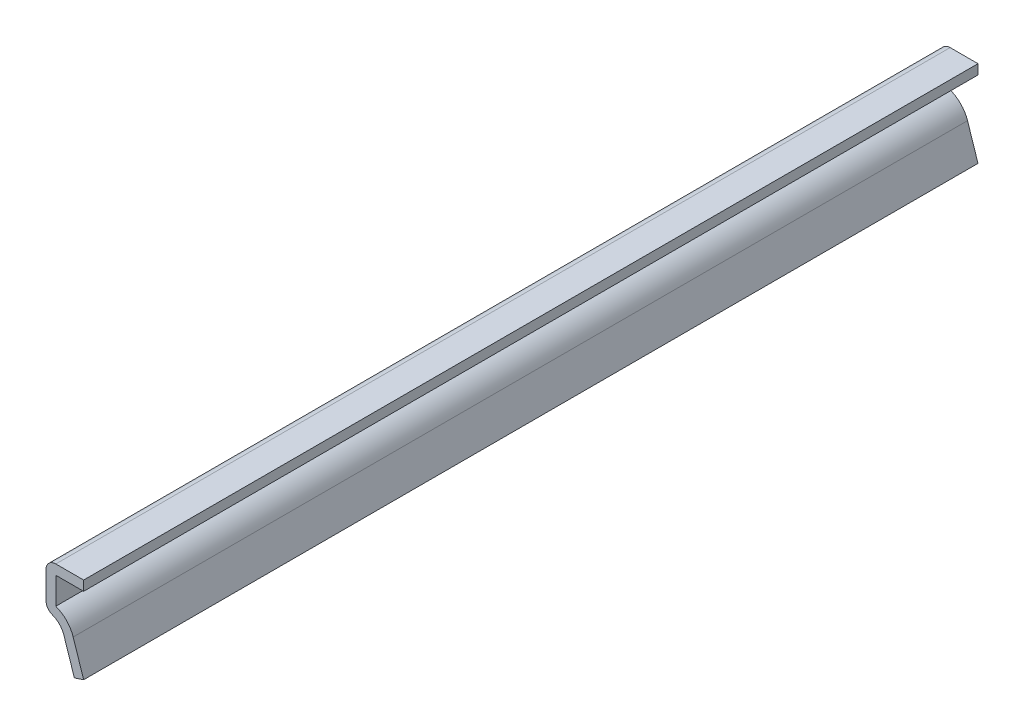
from build123d import *

# Parameters (mm, degrees)
EXTRUDE_THIN1_DEPTH = 150.8125
FILLET1_R           = 1.651


with BuildPart() as part:
    # Sketch1 → Extrude-Thin1 (new body)
    with BuildSketch(Plane.XY):
        with BuildLine():
            Line((0, 15.08125), (-6.35, 15.08125))
            Line((-6.35, 15.08125), (-6.35, 7.540625))
            ThreePointArc((-6.35, 7.540625), (-4.489227834, 6.938201907), (-3.334579839, 5.359539611))
            Line((-3.334579839, 5.359539611), (-1.568018484, 0))
            Line((-1.568018484, 0), (0, 0.516835598))
            Line((0, 0.516835598), (-1.766561356, 5.876375209))
            ThreePointArc((-1.766561356, 5.876375209), (-2.885424088, 7.725236547), (-4.699, 8.900432052))
            Line((-4.699, 8.900432052), (-4.699, 13.43025))
            Line((-4.699, 13.43025), (0, 13.43025))
            Line((0, 13.43025), (0, 15.08125))
        make_face()
    extrude(amount=-EXTRUDE_THIN1_DEPTH)

    # Fillet1
    fillet1_edges = [part.edges().sort_by_distance(p)[0] for p in [
        (-6.35, 7.540625, -75.40625),
        (-6.35, 15.08125, -75.40625),
    ]]
    fillet(fillet1_edges, radius=FILLET1_R)


solid = part.part
